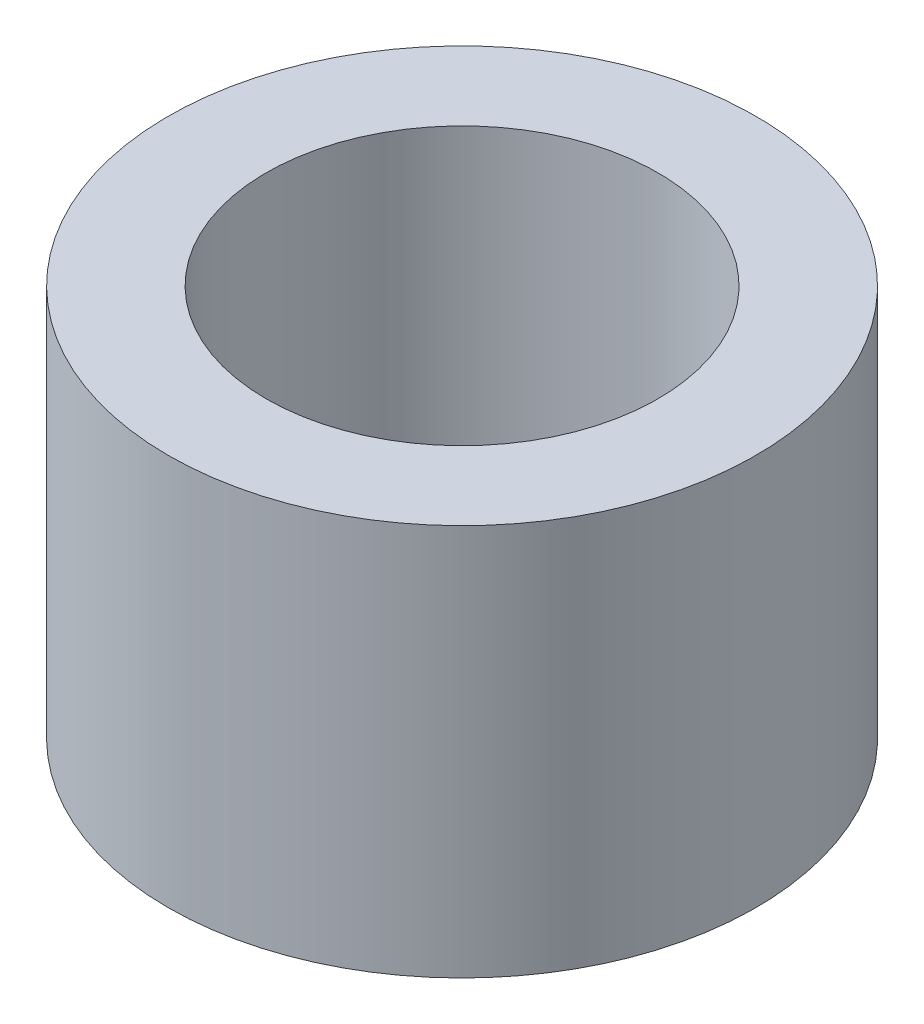
from build123d import *

# Parameters (mm, degrees)
SKIZZE1_R                       = 3
SKIZZE1_R_2                     = 2
AUFSATZ_LINEAR_AUSTRAGEN1_DEPTH = 4


with BuildPart() as part:
    # Skizze1 → Aufsatz-Linear austragen1 (new body)
    with BuildSketch(Plane(origin=(0, 0, 0), x_dir=(1, 0, 0), z_dir=(0, 1, 0))):
        Circle(SKIZZE1_R)
        Circle(SKIZZE1_R_2, mode=Mode.SUBTRACT)
    extrude(amount=AUFSATZ_LINEAR_AUSTRAGEN1_DEPTH)


solid = part.part
